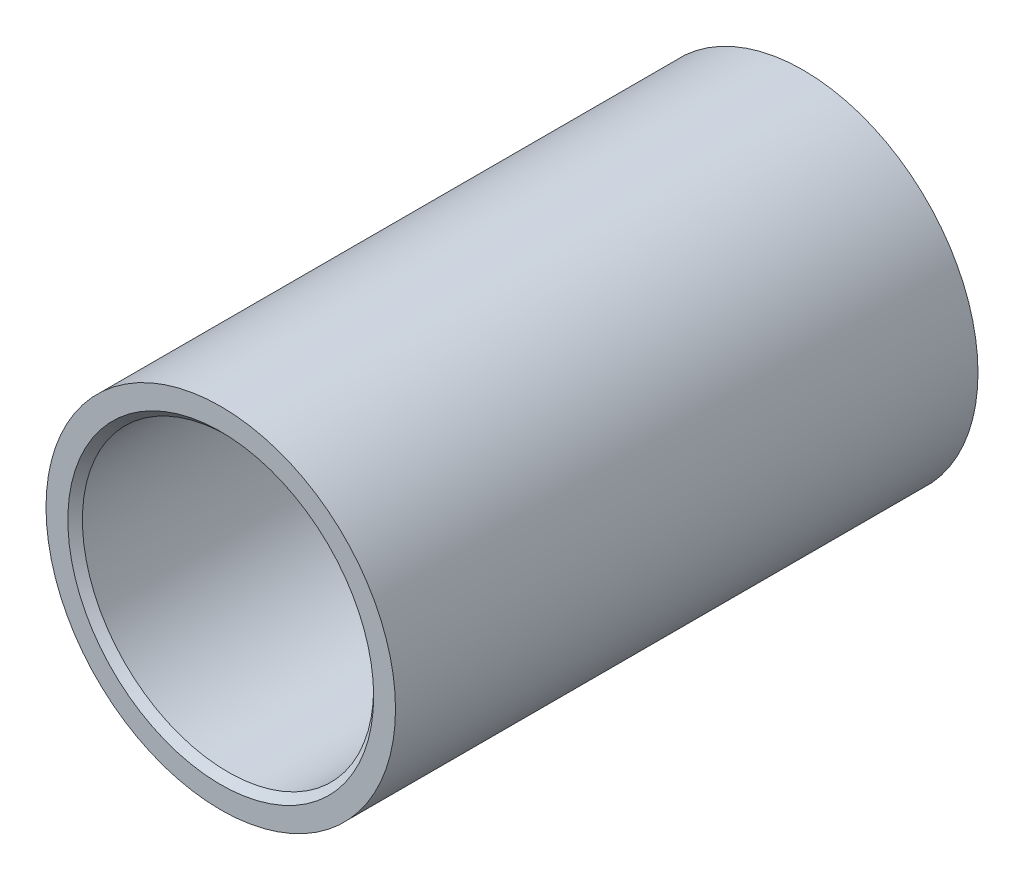
from build123d import *

# Parameters (mm, degrees)
SKETCH1_R           = 19.05
SKETCH1_R_2         = 13.49375
BOSS_EXTRUDE1_DEPTH = 31.75
SKETCH2_R           = 15.875
CUT_EXTRUDE1_DEPTH  = 26.9875
CHAMFER1_SIZE       = 0.79375


with BuildPart() as part:
    # Sketch1 → Boss-Extrude1 (new body)
    with BuildSketch(Plane.XY):
        Circle(SKETCH1_R)
        Circle(SKETCH1_R_2, mode=Mode.SUBTRACT)
    extrude(amount=BOSS_EXTRUDE1_DEPTH)

    # Sketch2 → Cut-Extrude1 (cut)
    with BuildSketch(Plane.XY.offset(31.75)):
        Circle(SKETCH2_R)
    extrude(amount=-CUT_EXTRUDE1_DEPTH, mode=Mode.SUBTRACT)

    # Mirror1: part across plane


with BuildPart() as part_1:
    add(part.part)
    add(part.part.mirror(Plane.XY))

    # Chamfer1
    chamfer1_edges = [part_1.edges().sort_by_distance(p)[0] for p in [
        (-15.875, 0, 31.75),
        (-15.875, 0, -31.75),
    ]]
    chamfer(chamfer1_edges, length=CHAMFER1_SIZE)


solid = part_1.part
